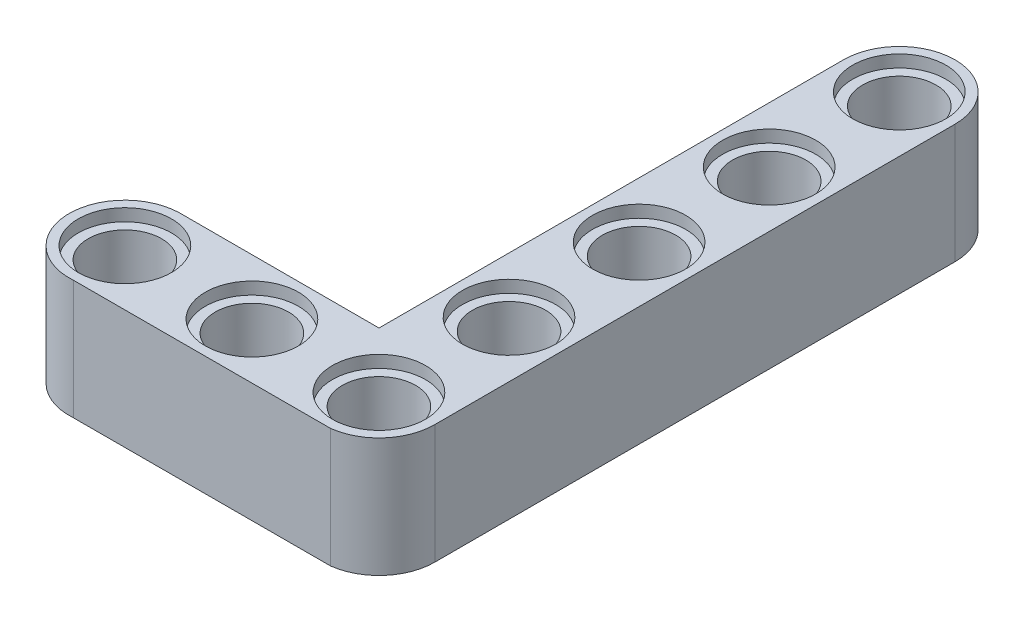
from build123d import *

# Parameters (mm, degrees)
SKETCH1_R           = 2.4
BOSS_EXTRUDE1_DEPTH = 7.8
SKETCH2_R           = 3.05
CUT_EXTRUDE1_DEPTH  = 0.8
SKETCH3_R           = 3.05
CUT_EXTRUDE2_DEPTH  = 0.8


with BuildPart() as part:
    # Sketch1 → Boss-Extrude1 (new body)
    with BuildSketch(Plane(origin=(0, 0, 0), x_dir=(1, 0, 0), z_dir=(0, 1, 0))):
        with BuildLine():
            Line((-39.256074834, -14.981858177), (-26.182604436, -14.980554672))
            Line((-26.182604436, -14.980554672), (-26.185636373, 15.428181457))
            ThreePointArc((-26.185636373, 15.428181457), (-22.535634636, 19.078177837), (-18.885638256, 15.428176099))
            Line((-18.885638256, 15.428176099), (-18.882245203, -18.602359628))
            ThreePointArc((-18.882245203, -18.602359628), (-19.783925456, -21.035198794), (-22.073348778, -22.255966806))
            Line((-22.073348778, -22.255966806), (-38.897547418, -22.273048621))
            ThreePointArc((-38.897547418, -22.273048621), (-42.812314517, -18.811138133), (-39.256074834, -14.981858177))
        make_face()
        with Locations((-39.165637315, -18.631821222)):
            Circle(SKETCH1_R, mode=Mode.SUBTRACT)
        with Locations((-30.850637315, -18.631821222)):
            Circle(SKETCH1_R, mode=Mode.SUBTRACT)
        with Locations((-22.535637315, -18.631821222)):
            Circle(SKETCH1_R, mode=Mode.SUBTRACT)
        with Locations((-22.535637315, 15.428178778)):
            Circle(SKETCH1_R, mode=Mode.SUBTRACT)
        with Locations((-22.535637315, 6.913178778)):
            Circle(SKETCH1_R, mode=Mode.SUBTRACT)
        with Locations((-22.535637315, -1.601821222)):
            Circle(SKETCH1_R, mode=Mode.SUBTRACT)
        with Locations((-22.535637315, -10.116821222)):
            Circle(SKETCH1_R, mode=Mode.SUBTRACT)
    extrude(amount=BOSS_EXTRUDE1_DEPTH)

    # Sketch2 → Cut-Extrude1 (cut)
    with BuildSketch(Plane(origin=(0, 7.8, 0), x_dir=(1, 0, 0), z_dir=(0, 1, 0))):
        with Locations((-39.165637315, -18.631821222)):
            Circle(SKETCH2_R)
        with Locations((-30.850637315, -18.631821222)):
            Circle(SKETCH2_R)
        with Locations((-22.535637315, -18.631821222)):
            Circle(SKETCH2_R)
        with Locations((-22.535637315, -10.116821222)):
            Circle(SKETCH2_R)
        with Locations((-22.535637315, -1.601821222)):
            Circle(SKETCH2_R)
        with Locations((-22.535637315, 6.913178778)):
            Circle(SKETCH2_R)
        with Locations((-22.535637315, 15.428178778)):
            Circle(SKETCH2_R)
    extrude(amount=-CUT_EXTRUDE1_DEPTH, mode=Mode.SUBTRACT)

    # Sketch3 → Cut-Extrude2 (cut)
    with BuildSketch(Plane.XZ):
        with Locations((-30.850637315, 18.631821222)):
            Circle(SKETCH3_R)
        with Locations((-39.165637315, 18.631821222)):
            Circle(SKETCH3_R)
        with Locations((-22.535637315, 18.631821222)):
            Circle(SKETCH3_R)
        with Locations((-22.535637315, 10.116821222)):
            Circle(SKETCH3_R)
        with Locations((-22.535637315, 1.601821222)):
            Circle(SKETCH3_R)
        with Locations((-22.535637315, -6.913178778)):
            Circle(SKETCH3_R)
        with Locations((-22.535637315, -15.428178778)):
            Circle(SKETCH3_R)
    extrude(amount=-CUT_EXTRUDE2_DEPTH, mode=Mode.SUBTRACT)


solid = part.part
